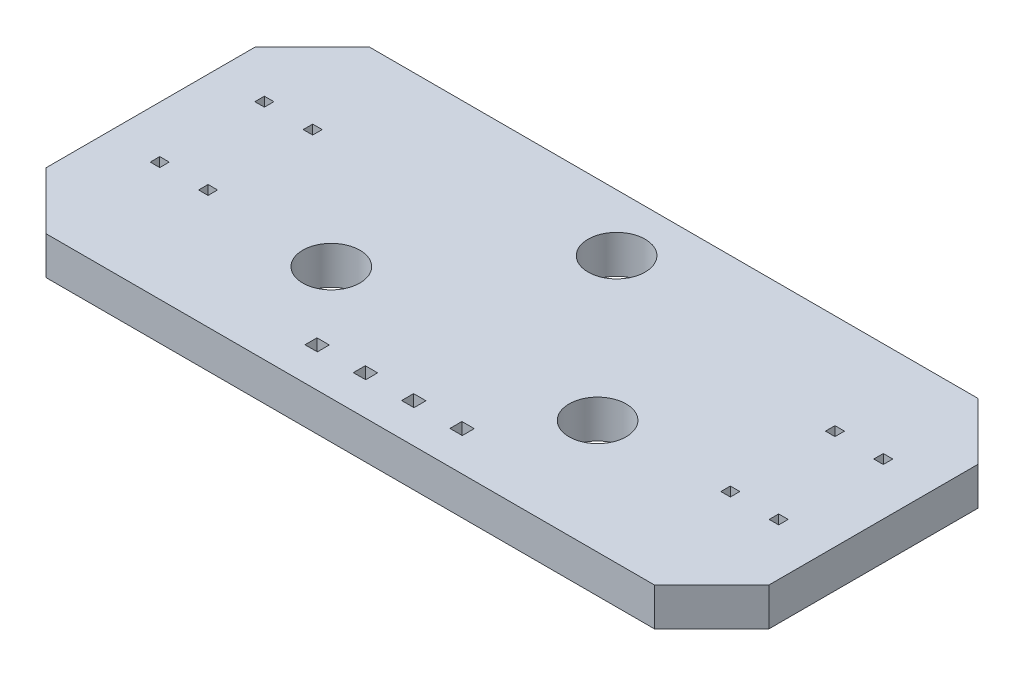
from build123d import *

# Parameters (mm, degrees)
SKETCH1_R           = 1.5
SKETCH1_W           = 0.5
SKETCH1_H           = 0.5
SKETCH1_W_2         = 0.65
SKETCH1_H_2         = 0.63
BOSS_EXTRUDE1_DEPTH = 2


with BuildPart() as part:
    # Sketch1 → Boss-Extrude1 (new body)
    with BuildSketch(Plane(origin=(0, 0, 0), x_dir=(1, 0, 0), z_dir=(0, 1, 0))):
        Polygon((-19, 5), (-19, -6), (-16, -9), (16, -9), (19, -6), (19, 5), (16, 8), (-16, 8), align=None)
        with Locations((-7, -3)):
            Circle(SKETCH1_R, mode=Mode.SUBTRACT)
        with Locations((7, -3)):
            Circle(SKETCH1_R, mode=Mode.SUBTRACT)
        with Locations((0, 5)):
            Circle(SKETCH1_R, mode=Mode.SUBTRACT)
        with Locations((-16.27, 2.75)):
            Rectangle(SKETCH1_W, SKETCH1_H, mode=Mode.SUBTRACT)
        with Locations((-16.27, -2.75)):
            Rectangle(SKETCH1_W, SKETCH1_H, mode=Mode.SUBTRACT)
        with Locations((-13.73, -2.75)):
            Rectangle(SKETCH1_W, SKETCH1_H, mode=Mode.SUBTRACT)
        with Locations((-13.73, 2.75)):
            Rectangle(SKETCH1_W, SKETCH1_H, mode=Mode.SUBTRACT)
        with Locations((13.73, 2.75)):
            Rectangle(SKETCH1_W, SKETCH1_H, mode=Mode.SUBTRACT)
        with Locations((13.73, -2.75)):
            Rectangle(SKETCH1_W, SKETCH1_H, mode=Mode.SUBTRACT)
        with Locations((16.27, -2.75)):
            Rectangle(SKETCH1_W, SKETCH1_H, mode=Mode.SUBTRACT)
        with Locations((16.27, 2.75)):
            Rectangle(SKETCH1_W, SKETCH1_H, mode=Mode.SUBTRACT)
        with Locations((-3.81, -6.934)):
            Rectangle(SKETCH1_W_2, SKETCH1_H_2, mode=Mode.SUBTRACT)
        with Locations((-1.27, -6.934)):
            Rectangle(SKETCH1_W_2, SKETCH1_H_2, mode=Mode.SUBTRACT)
        with Locations((1.27, -6.934)):
            Rectangle(SKETCH1_W_2, SKETCH1_H_2, mode=Mode.SUBTRACT)
        with Locations((3.81, -6.934)):
            Rectangle(SKETCH1_W_2, SKETCH1_H_2, mode=Mode.SUBTRACT)
    extrude(amount=BOSS_EXTRUDE1_DEPTH)


solid = part.part
